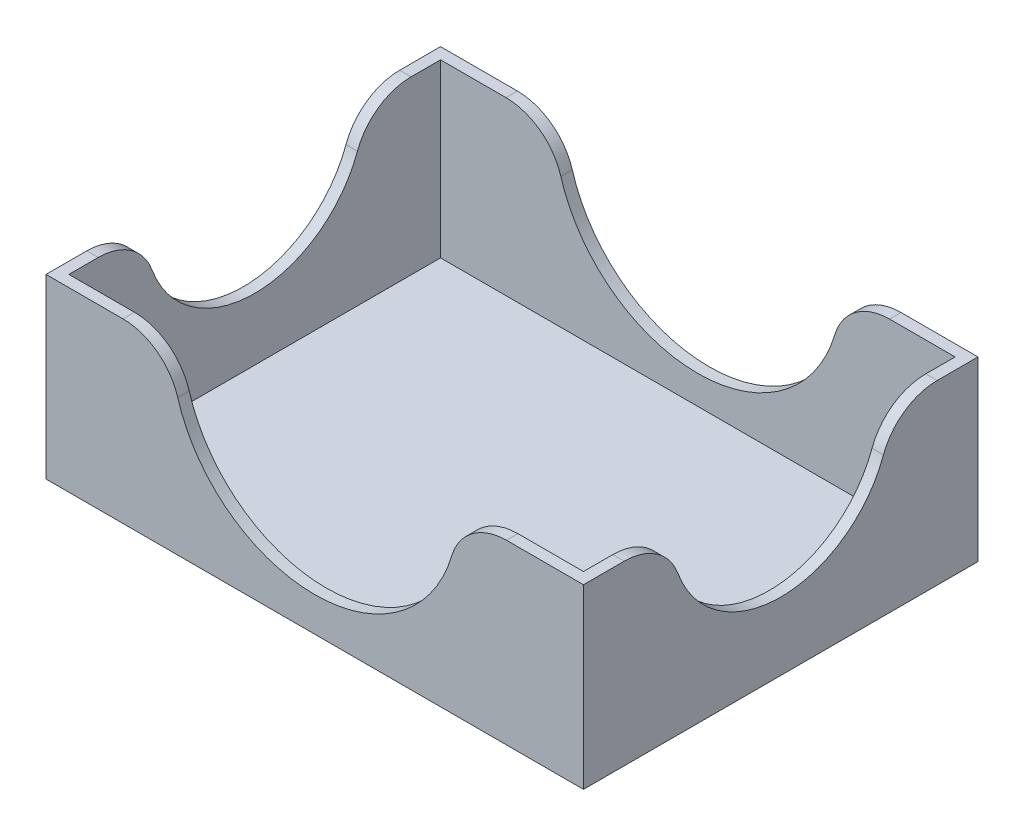
from build123d import *

# Parameters (mm, degrees)
SKETCH3_W               = 94
SKETCH3_H               = 69
SKETCH3_W_2             = 90
SKETCH3_H_2             = 65
BOSS_EXTRUDE3_DEPTH     = 30
SKETCH4_W               = 94
SKETCH4_H               = 69
BOSS_EXTRUDE4_DEPTH     = 1
SKETCH5_R               = 19.129928065
CUT_EXTRUDE1_DEPTH      = 1
CUT_EXTRUDE1_DEPTH_BACK = 95
FILLET1_R               = 10
SKETCH6_R               = 25
CUT_EXTRUDE2_DEPTH      = 1
CUT_EXTRUDE2_DEPTH_BACK = 70
FILLET2_R               = 10


with BuildPart() as part:
    # Sketch3 → Boss-Extrude3 (new body)
    with BuildSketch(Plane(origin=(0, 0, 0), x_dir=(1, 0, 0), z_dir=(0, 1, 0))):
        with Locations((0, -4.625984252)):
            Rectangle(SKETCH3_W, SKETCH3_H)
        with Locations((0, -4.625984252)):
            Rectangle(SKETCH3_W_2, SKETCH3_H_2, mode=Mode.SUBTRACT)
    extrude(amount=BOSS_EXTRUDE3_DEPTH)

    # Sketch4 → Boss-Extrude4 (add)
    with BuildSketch(Plane.XZ):
        with Locations((0, 4.625984252)):
            Rectangle(SKETCH4_W, SKETCH4_H)
    extrude(amount=BOSS_EXTRUDE4_DEPTH)

    # Sketch5 → Cut-Extrude1 (cut, two sides)
    with BuildSketch(Plane(origin=(47, 0, 0), x_dir=(0, 0, -1), z_dir=(1, 0, 0))) as cut_extrude1_sk:
        with Locations((-4.625984252, 30)):
            Circle(SKETCH5_R)
    extrude(amount=CUT_EXTRUDE1_DEPTH, mode=Mode.SUBTRACT)
    extrude(cut_extrude1_sk.sketch, amount=-CUT_EXTRUDE1_DEPTH_BACK, mode=Mode.SUBTRACT)

    # Fillet1
    fillet1_edges = [part.edges().sort_by_distance(p)[0] for p in [
        (46, 30, -14.503943813),
        (46, 30, 23.755912317),
        (-46, 30, 23.755912317),
        (-46, 30, -14.503943813),
    ]]
    fillet(fillet1_edges, radius=FILLET1_R)

    # Sketch6 → Cut-Extrude2 (cut, two sides)
    with BuildSketch(Plane(origin=(0, 0, -29.874015748), x_dir=(-1, 0, 0), z_dir=(0, 0, -1))) as cut_extrude2_sk:
        with Locations((0, 30)):
            Circle(SKETCH6_R)
    extrude(amount=CUT_EXTRUDE2_DEPTH, mode=Mode.SUBTRACT)
    extrude(cut_extrude2_sk.sketch, amount=-CUT_EXTRUDE2_DEPTH_BACK, mode=Mode.SUBTRACT)

    # Fillet2
    fillet2_edges = [part.edges().sort_by_distance(p)[0] for p in [
        (25, 30, -28.874015748),
        (-25, 30, -28.874015748),
        (25, 30, 38.125984252),
        (-25, 30, 38.125984252),
    ]]
    fillet(fillet2_edges, radius=FILLET2_R)


solid = part.part
